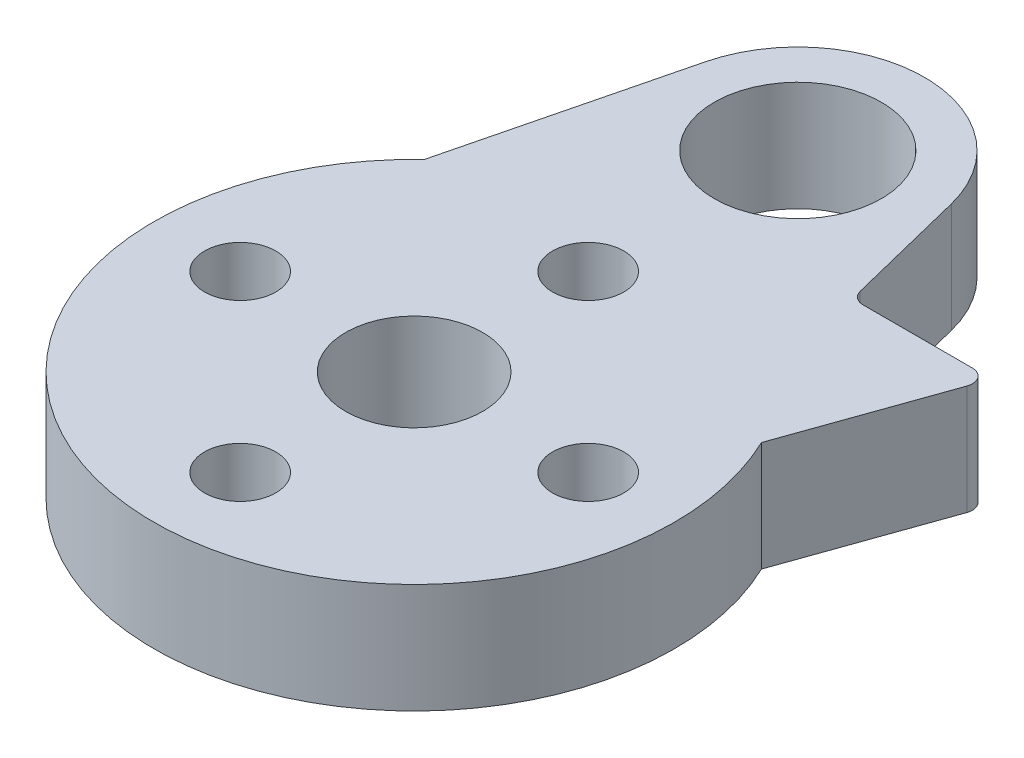
from build123d import *

# Parameters (mm, degrees)
SKETCH1_R           = 3.05
SKETCH1_R_2         = 2.5
BOSS_EXTRUDE1_DEPTH = 4
SKETCH2_R           = 1.3
CUT_EXTRUDE1_DEPTH  = 4
SKETCH3_R           = 7.65
BOSS_EXTRUDE2_DEPTH = 4
BOSS_EXTRUDE3_DEPTH = 4
FILLET9_R           = 0.5


with BuildPart() as part:
    # Sketch1 → Boss-Extrude1 (new body)
    with BuildSketch(Plane(origin=(0, 0, 0), x_dir=(1, 0, 0), z_dir=(0, 1, 0))):
        with BuildLine():
            Line((-4.488689239, 15.114947499), (-7.764071496, 1.928521143))
            ThreePointArc((-7.764071496, 1.928521143), (0, -8), (7.764071496, 1.928521143))
            Line((7.764071496, 1.928521143), (4.488689239, 15.114947499))
            ThreePointArc((4.488689239, 15.114947499), (0, 18.625088), (-4.488689239, 15.114947499))
        make_face()
        with Locations((0, 14)):
            Circle(SKETCH1_R, mode=Mode.SUBTRACT)
        Circle(SKETCH1_R_2, mode=Mode.SUBTRACT)
    extrude(amount=BOSS_EXTRUDE1_DEPTH)

    # Sketch2 → Cut-Extrude1 (cut)
    with BuildSketch(Plane(origin=(0, 4, 0), x_dir=(1, 0, 0), z_dir=(0, 1, 0))):
        with Locations((0, 6.35)):
            Circle(SKETCH2_R)
        with Locations((6.35, 0)):
            Circle(SKETCH2_R)
        with Locations((0, -6.35)):
            Circle(SKETCH2_R)
        with Locations((-6.35, 0)):
            Circle(SKETCH2_R)
    extrude(amount=-CUT_EXTRUDE1_DEPTH, mode=Mode.SUBTRACT)

    # Sketch3 → Boss-Extrude2 (add)
    with BuildSketch(Plane(origin=(0, 4, 0), x_dir=(1, 0, 0), z_dir=(0, 1, 0))):
        with BuildLine():
            ThreePointArc((-1.549317863, 9.3728125), (0, -9.5), (1.549317863, 9.3728125))
            ThreePointArc((1.549317863, 9.3728125), (0, 9.120322757), (-1.549317863, 9.3728125))
        make_face()
        Circle(SKETCH3_R, mode=Mode.SUBTRACT)
    extrude(amount=-BOSS_EXTRUDE2_DEPTH)

    # Sketch4 → Boss-Extrude3 (add)
    with BuildSketch(Plane(origin=(0, 4, 0), x_dir=(1, 0, 0), z_dir=(0, 1, 0))):
        with BuildLine():
            Line((10.767160229, 10.309478294), (8.567165836, 4.1053221))
            Line((8.567165836, 4.1053221), (2.165063509, 1.25))
            ThreePointArc((2.165063509, 1.25), (1.994303817, 1.507565019), (1.793071605, 1.742094779))
            Line((1.793071605, 1.742094779), (5.682321854, 10.309478294))
            Line((5.682321854, 10.309478294), (10.767160229, 10.309478294))
        make_face()
    extrude(amount=-BOSS_EXTRUDE3_DEPTH)

    # Fillet9
    fillet9_edges = [part.edges().sort_by_distance(p)[0] for p in [
        (5.682321854, 2, -10.309478294),
        (10.767160229, 2, -10.309478294),
    ]]
    fillet(fillet9_edges, radius=FILLET9_R)


solid = part.part
